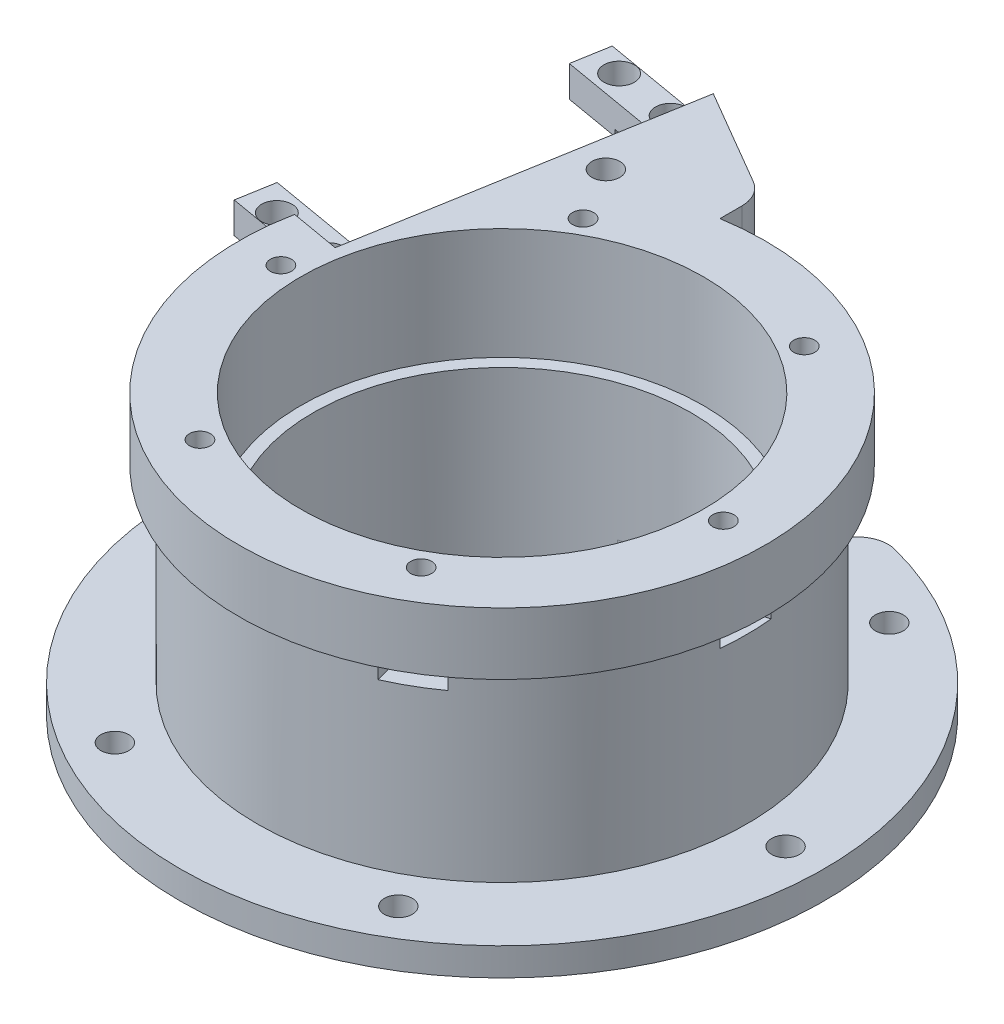
from build123d import *

# Parameters (mm, degrees)
SKETCH1_W                = 2
SKETCH1_H                = 27
M4_CLEARANCE_HOLE1_D     = 4.5
M4_CLEARANCE_HOLE1_DEPTH = 4.5
CUT_EXTRUDE1_START       = -10
CUT_EXTRUDE1_DEPTH       = 4
CIRPATTERN3_COUNT        = 6
SKETCH7_W                = 13.590111476
SKETCH7_H                = 85.87559673
CUT_EXTRUDE2_DEPTH       = 5
FILLET1_R                = 5
CUT_EXTRUDE3_DEPTH       = 46
BOSS_EXTRUDE1_START      = -9.8884
SKETCH8_3_R              = 2.45
BOSS_EXTRUDE1_DEPTH      = 1
BOSS_EXTRUDE2_START      = -8.8884
SKETCH8_4_R              = 2.45
BOSS_EXTRUDE2_DEPTH      = 4
BOSS_EXTRUDE3_DEPTH      = 37
BOSS_EXTRUDE4_START      = -2
SKETCH12_R               = 2.25
BOSS_EXTRUDE4_DEPTH      = 10


with BuildPart() as part:
    # Sketch1 → Revolve1 (revolve)
    with BuildSketch(Plane.XY):
        Polygon((32.5, 0), (39.5, 0), (52, 0), (52, 4.5), (39.5, 4.5), (39.5, 35), (42.5, 35), (42.5, 45), (32.5, 45), (32.5, 38), (32.5, 33), (32.5, 27), align=None)
        with Locations((31.5, 13.5)):
            Rectangle(SKETCH1_W, SKETCH1_H)
    revolve(axis=Axis((0, 0, 0), (0, 1, 0)))

    # M4 Clearance Hole1
    with Locations(Plane(origin=(0, 4.5, 0), x_dir=(1, 0, 0), z_dir=(0, 1, 0))):
        with Locations((45.75, 0)):
            m4_clearance_hole1 = Hole(M4_CLEARANCE_HOLE1_D / 2, depth=M4_CLEARANCE_HOLE1_DEPTH)

    # Sketch5 → M3 Clearance Hole1 (revolve, cut)
    with BuildSketch(Plane(origin=(35.7, 45, 0), x_dir=(0, 0, 1), z_dir=(1, 0, 0))):
        Polygon((0, 0), (0, 11.021463052), (1.7, 10), (1.7, 0), align=None)
    m3_clearance_hole1 = revolve(axis=Axis((35.7, 51.35, 0), (0, -1, 0)), mode=Mode.SUBTRACT)

    # Sketch4_2 → Cut-Extrude1 (cut)
    with BuildSketch(Plane(origin=(0, 45, 0), x_dir=(1, 0, 0), z_dir=(0, 1, 0)).offset(CUT_EXTRUDE1_START)):
        with BuildLine():
            Line((38.45, 1.58771324), (38.45, -1.58771324))
            Line((38.45, -1.58771324), (35.7, -3.175426481))
            Line((35.7, -3.175426481), (42.214154639, -4.920888955))
            ThreePointArc((42.214154639, -4.920888955), (42.428478479, -2.464592039), (42.5, 0))
            ThreePointArc((42.5, 0), (42.428478479, 2.464592039), (42.214154639, 4.920888955))
            Line((42.214154639, 4.920888955), (35.7, 3.175426481))
            Line((35.7, 3.175426481), (38.45, 1.58771324))
        make_face()
        Polygon((32.95, -1.58771324), (35.7, -3.175426481), (38.45, -1.58771324), (38.45, 1.58771324), (35.7, 3.175426481), (32.95, 1.58771324), align=None)
    cut_extrude1 = extrude(amount=-CUT_EXTRUDE1_DEPTH, mode=Mode.SUBTRACT)

    # CirPattern3: M4 Clearance Hole1, M3 Clearance Hole1, Cut-Extrude1 ×6 about axis
    cirpattern3_axis = Axis((0, 0, 0), (0, 1, 0))
    for i in range(1, CIRPATTERN3_COUNT):
        add(m4_clearance_hole1.rotate(cirpattern3_axis, i * 360 / CIRPATTERN3_COUNT), mode=Mode.SUBTRACT)
        add(m3_clearance_hole1.rotate(cirpattern3_axis, i * 360 / CIRPATTERN3_COUNT), mode=Mode.SUBTRACT)
        add(cut_extrude1.rotate(cirpattern3_axis, i * 360 / CIRPATTERN3_COUNT), mode=Mode.SUBTRACT)

    # Sketch7 → Cut-Extrude2 (cut)
    with BuildSketch(Plane.XZ):
        with Locations((0, -42.937798365)):
            Rectangle(SKETCH7_W, SKETCH7_H)
    extrude(amount=-CUT_EXTRUDE2_DEPTH, mode=Mode.SUBTRACT)

    # Fillet1
    fillet1_edges = [part.edges().sort_by_distance(p)[0] for p in [
        (-6.795055738, 2.5, -29.733436019),
        (-6.795055738, 2.25, -51.554119307),
        (6.795055738, 2.5, -29.733436019),
        (6.795055738, 2.25, -51.554119307),
    ]]
    fillet(fillet1_edges, radius=FILLET1_R)

    # Sketch8 → Cut-Extrude3 (cut, through all)
    with BuildSketch(Plane(origin=(0, 45, 0), x_dir=(1, 0, 0), z_dir=(0, 1, 0))):
        Polygon((-33.77753348, 6.841230885), (-24.786528121, 58.870086558), (-44.494427997, 62.275770406), (-53.485433356, 10.246914732), align=None)
    extrude(amount=-CUT_EXTRUDE3_DEPTH, mode=Mode.SUBTRACT)

    # Sketch8_3 → Boss-Extrude1 (add)
    with BuildSketch(Plane(origin=(0, 45, 0), x_dir=(1, 0, 0), z_dir=(0, 1, 0)).offset(BOSS_EXTRUDE1_START)):
        Polygon((-34.67678822, 54.490274326), (-25.808233276, 52.957716595), (-24.786528121, 58.870086558), (-33.655083065, 60.402644289), align=None)
        with Locations((-30.040674072, 57.240991616)):
            Circle(SKETCH8_3_R, mode=Mode.SUBTRACT)
        Polygon((-45.516133152, 56.363400443), (-36.647578207, 54.830842711), (-35.625873053, 60.743212674), (-44.494427997, 62.275770406), align=None)
        with Locations((-40.091703009, 58.977890378)):
            Circle(SKETCH8_3_R, mode=Mode.SUBTRACT)
        Polygon((-53.485433356, 10.246914732), (-44.616878412, 8.714357001), (-43.595173257, 14.626726964), (-52.463728201, 16.159284695), align=None)
        with Locations((-48.231287405, 11.876009674)):
            Circle(SKETCH8_3_R, mode=Mode.SUBTRACT)
        with BuildLine():
            Line((-41.699432083, 8.210198775), (-33.77753348, 6.841230885))
            Line((-33.77753348, 6.841230885), (-32.755828325, 12.753600847))
            Line((-32.755828325, 12.753600847), (-40.118843779, 14.025989228))
            ThreePointArc((-40.118843779, 14.025989228), (-41.01235693, 11.146146378), (-41.699432083, 8.210198775))
        make_face()
        with Locations((-38.180258468, 10.139110912)):
            Circle(SKETCH8_3_R, mode=Mode.SUBTRACT)
    extrude(amount=BOSS_EXTRUDE1_DEPTH)

    # Sketch8_4 → Boss-Extrude2 (add)
    with BuildSketch(Plane(origin=(0, 45, 0), x_dir=(1, 0, 0), z_dir=(0, 1, 0)).offset(BOSS_EXTRUDE2_START)):
        Polygon((-34.67678822, 54.490274326), (-25.808233276, 52.957716595), (-24.786528121, 58.870086558), (-33.655083065, 60.402644289), align=None)
        with Locations((-30.040674072, 57.240991616)):
            Circle(SKETCH8_4_R, mode=Mode.SUBTRACT)
        Polygon((-45.516133152, 56.363400443), (-36.647578207, 54.830842711), (-35.625873053, 60.743212674), (-44.494427997, 62.275770406), align=None)
        with Locations((-40.091703009, 58.977890378)):
            Circle(SKETCH8_4_R, mode=Mode.SUBTRACT)
        Polygon((-36.647578207, 54.830842711), (-34.67678822, 54.490274326), (-33.655083065, 60.402644289), (-35.625873053, 60.743212674), align=None)
        Polygon((-53.485433356, 10.246914732), (-44.616878412, 8.714357001), (-43.595173257, 14.626726964), (-52.463728201, 16.159284695), align=None)
        with Locations((-48.231287405, 11.876009674)):
            Circle(SKETCH8_4_R, mode=Mode.SUBTRACT)
        Polygon((-44.616878412, 8.714357001), (-42.646088424, 8.373788616), (-41.62438327, 14.286158579), (-43.595173257, 14.626726964), align=None)
        with BuildLine():
            Line((-41.699432083, 8.210198775), (-33.77753348, 6.841230885))
            Line((-33.77753348, 6.841230885), (-32.755828325, 12.753600847))
            Line((-32.755828325, 12.753600847), (-40.118843779, 14.025989228))
            ThreePointArc((-40.118843779, 14.025989228), (-41.01235693, 11.146146378), (-41.699432083, 8.210198775))
        make_face()
        with Locations((-38.180258468, 10.139110912)):
            Circle(SKETCH8_4_R, mode=Mode.SUBTRACT)
        with BuildLine():
            Line((-42.646088424, 8.373788616), (-41.699432083, 8.210198775))
            ThreePointArc((-41.699432083, 8.210198775), (-41.01235693, 11.146146378), (-40.118843779, 14.025989228))
            Line((-40.118843779, 14.025989228), (-41.62438327, 14.286158579))
            Line((-41.62438327, 14.286158579), (-42.646088424, 8.373788616))
        make_face()
    extrude(amount=BOSS_EXTRUDE2_DEPTH)

    # Sketch11 → Boss-Extrude3 (add)
    with BuildSketch(Plane.XZ):
        with BuildLine():
            Line((-27.313133013, -44.249212027), (-24.786528121, -58.870086558))
            Line((-24.786528121, -58.870086558), (-9.274181519, -49.813905189))
            ThreePointArc((-9.274181519, -49.813905189), (-11.110324868, -50.448789631), (-13.049848902, -50.335886241))
            ThreePointArc((-13.049848902, -50.335886241), (-20.409666288, -47.827246649), (-27.313133013, -44.249212027))
        make_face()
    extrude(amount=-BOSS_EXTRUDE3_DEPTH)

    # Sketch12 → Boss-Extrude4 (add)
    with BuildSketch(Plane(origin=(0, 37, 0), x_dir=(1, 0, 0), z_dir=(0, 1, 0)).offset(BOSS_EXTRUDE4_START)):
        with BuildLine():
            ThreePointArc((-6.795055738, 45.495897179), (-7.45890719, 47.985438456), (-9.274182045, 49.813905496))
            Line((-9.274182045, 49.813905496), (-24.786528121, 58.870086558))
            Line((-24.786528121, 58.870086558), (-30.655076171, 24.910164692))
            ThreePointArc((-30.655076171, 24.910164692), (-19.990871879, 34.067800655), (-6.795055738, 38.911145158))
            Line((-6.795055738, 38.911145158), (-6.795055738, 45.495897179))
        make_face()
        with Locations((-22.875, 39.620662223)):
            Circle(SKETCH12_R, mode=Mode.SUBTRACT)
    extrude(amount=BOSS_EXTRUDE4_DEPTH)


solid = part.part
